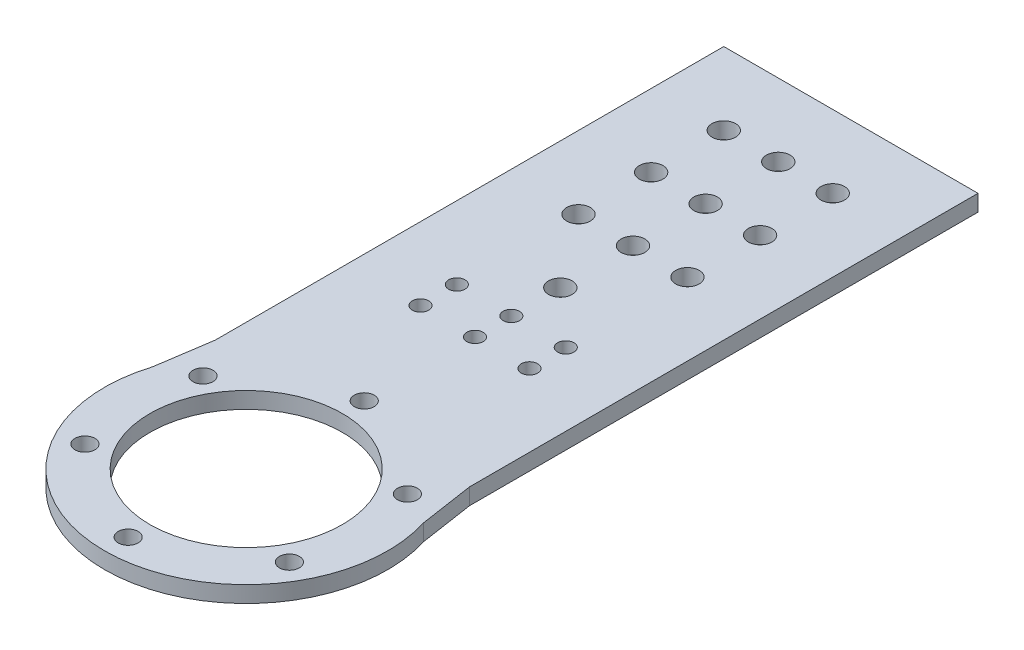
from build123d import *

# Parameters (mm, degrees)
SKETCH1_R            = 39
SKETCH1_R_2          = 26.5
BOSS_EXTRUDE1_DEPTH  = 2.25
SKETCH3_W            = 50
SKETCH3_H            = 51.5
BOSS_EXTRUDE2_DEPTH  = 2.25
BOSS_EXTRUDE4_DEPTH  = 2.25
SKETCH2_R            = 2.75
CUT_EXTRUDE1_DEPTH   = 3.25
CIRPATTERN1_COUNT    = 6
CUT_EXTRUDE2_START   = -5.5
SKETCH5_R            = 2.25
CUT_EXTRUDE2_DEPTH   = 6.5
LPATTERN1_COUNT      = 2
LPATTERN1_PITCH      = 15
LPATTERN1_COUNT_DIR2 = 2
LPATTERN1_PITCH_DIR2 = 10
LPATTERN2_COUNT      = 2
LPATTERN2_PITCH      = 15
LPATTERN2_COUNT_DIR2 = 2
LPATTERN2_PITCH_DIR2 = 10
CUT_EXTRUDE3_START   = -5.5
SKETCH7_R            = 3.25
CUT_EXTRUDE3_DEPTH   = 6.5
LPATTERN3_COUNT      = 3
LPATTERN3_PITCH      = 20
SKETCH8_R            = 3.25
CUT_EXTRUDE4_DEPTH   = 10
LPATTERN4_COUNT      = 4
LPATTERN4_PITCH      = 20


with BuildPart() as part:
    # Sketch1 → Boss-Extrude1 (new body, symmetric)
    with BuildSketch(Plane(origin=(0, 0, 0), x_dir=(1, 0, 0), z_dir=(0, 1, 0))):
        Circle(SKETCH1_R)
        Circle(SKETCH1_R_2, mode=Mode.SUBTRACT)
    extrude(amount=BOSS_EXTRUDE1_DEPTH, both=True)

    # Sketch3 → Boss-Extrude2 (add, symmetric)
    with BuildSketch(Plane(origin=(0, 0, 0), x_dir=(1, 0, 0), z_dir=(0, 1, 0))):
        with Locations((0, 52.25)):
            Rectangle(SKETCH3_W, SKETCH3_H)
    extrude(amount=BOSS_EXTRUDE2_DEPTH, both=True)

    # Sketch6 → Boss-Extrude4 (add, symmetric)
    with BuildSketch(Plane(origin=(0, 0, 0), x_dir=(1, 0, 0), z_dir=(0, 1, 0))):
        Polygon((-35, 166.5), (-35, 26.5), (-39, 0), (-14.981514186, 26.5), (16.520833333, 26.5), (39, 0), (35, 26.5), (35, 166.5), align=None)
    extrude(amount=BOSS_EXTRUDE4_DEPTH, both=True)

    # Sketch2 → Cut-Extrude1 (cut, symmetric)
    with BuildSketch(Plane(origin=(0, 0, 0), x_dir=(1, 0, 0), z_dir=(0, 1, 0))):
        with Locations((0, 32.5)):
            Circle(SKETCH2_R)
    cut_extrude1 = extrude(amount=CUT_EXTRUDE1_DEPTH, both=True, mode=Mode.SUBTRACT)

    # CirPattern1: Cut-Extrude1 ×6 about axis
    cirpattern1_axis = Axis((0, 0, 0), (0, 1, 0))
    for i in range(1, CIRPATTERN1_COUNT):
        add(cut_extrude1.rotate(cirpattern1_axis, i * 360 / CIRPATTERN1_COUNT), mode=Mode.SUBTRACT)

    # Sketch5 → Cut-Extrude2 (cut)
    with BuildSketch(Plane(origin=(0, 2.25, 0), x_dir=(1, 0, 0), z_dir=(0, 1, 0)).offset(CUT_EXTRUDE2_START)):
        with Locations((0, 73)):
            Circle(SKETCH5_R)
    cut_extrude2 = extrude(amount=CUT_EXTRUDE2_DEPTH, mode=Mode.SUBTRACT)

    # LPattern1: Cut-Extrude2 2 × 2
    with Locations(*[(i * LPATTERN1_PITCH, 0, j * LPATTERN1_PITCH_DIR2) for i in range(LPATTERN1_COUNT) for j in range(LPATTERN1_COUNT_DIR2) if (i, j) != (0, 0)]):
        add(cut_extrude2, mode=Mode.SUBTRACT)

    # LPattern2: Cut-Extrude2 2 × 2
    with Locations(*[(-i * LPATTERN2_PITCH, 0, j * LPATTERN2_PITCH_DIR2) for i in range(LPATTERN2_COUNT) for j in range(LPATTERN2_COUNT_DIR2) if (i, j) != (0, 0)]):
        add(cut_extrude2, mode=Mode.SUBTRACT)

    # Sketch7 → Cut-Extrude3 (cut)
    with BuildSketch(Plane(origin=(0, 2.25, 0), x_dir=(1, 0, 0), z_dir=(0, 1, 0)).offset(CUT_EXTRUDE3_START)):
        with Locations((-15, 146.5)):
            Circle(SKETCH7_R)
        with Locations((15, 146.5)):
            Circle(SKETCH7_R)
    cut_extrude3 = extrude(amount=CUT_EXTRUDE3_DEPTH, mode=Mode.SUBTRACT)

    # LPattern3: Cut-Extrude3 ×3
    with Locations(*[(0, 0, i * LPATTERN3_PITCH) for i in range(1, LPATTERN3_COUNT)]):
        add(cut_extrude3, mode=Mode.SUBTRACT)

    # Sketch8 → Cut-Extrude4 (cut)
    with BuildSketch(Plane(origin=(0, 2.25, 0), x_dir=(1, 0, 0), z_dir=(0, 1, 0))):
        with Locations((0, 146.5)):
            Circle(SKETCH8_R)
    cut_extrude4 = extrude(amount=-CUT_EXTRUDE4_DEPTH, mode=Mode.SUBTRACT)

    # LPattern4: Cut-Extrude4 ×4
    with Locations(*[(0, 0, i * LPATTERN4_PITCH) for i in range(1, LPATTERN4_COUNT)]):
        add(cut_extrude4, mode=Mode.SUBTRACT)


solid = part.part
